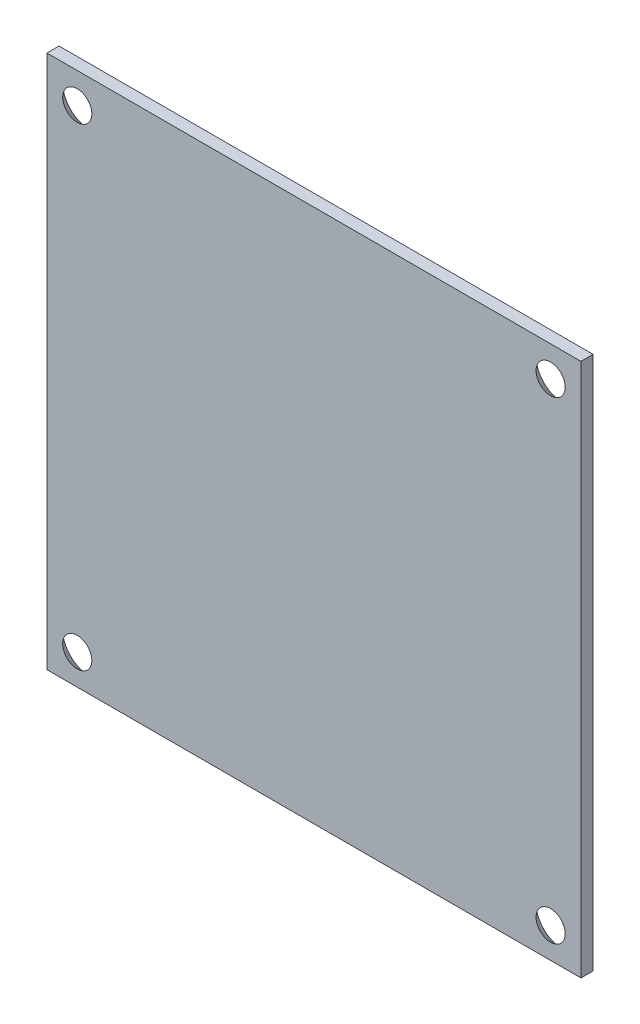
from build123d import *

# Parameters (mm, degrees)
ESQUISSE1_W                                 = 44
ESQUISSE1_H                                 = 44
BOSS_EXTRU_1_DEPTH                          = 1
FRAISAGE_POUR_VIS_T_TE_FRAIS_E_M21_AT_COUNT = 2
FRAISAGE_POUR_VIS_T_TE_FRAIS_E_M21_AT_PITCH = 39


with BuildPart() as part:
    # Esquisse1 → Boss.-Extru.1 (new body)
    with BuildSketch(Plane(origin=(0, 0, 0), x_dir=(0, 1, 0), z_dir=(0, 0, 1))):
        Rectangle(ESQUISSE1_W, ESQUISSE1_H)
    extrude(amount=BOSS_EXTRU_1_DEPTH)

    # Esquisse3 → Fraisage pour vis à tête fraisée M21 (revolve, cut)
    with BuildSketch(Plane(origin=(19.5, 19.5, 0), x_dir=(0, 1, 0), z_dir=(1, 0, 0))):
        Polygon((0, 0), (0, 2), (1.2, 2), (1.2, 1), (2.2, 0), align=None)
    fraisage_pour_vis_t_te_frais_e_m21 = revolve(axis=Axis((19.5, 19.5, -6.35), (0, 0, 1)), mode=Mode.SUBTRACT)

    # Fraisage pour vis à tête fraisée M21 at: Fraisage pour vis à tête fraisée M21 ×2
    with Locations(*[(-i * FRAISAGE_POUR_VIS_T_TE_FRAIS_E_M21_AT_PITCH, 0, 0) for i in range(1, FRAISAGE_POUR_VIS_T_TE_FRAIS_E_M21_AT_COUNT)]):
        add(fraisage_pour_vis_t_te_frais_e_m21, mode=Mode.SUBTRACT)

    # Symétrie2: Fraisage pour vis à tête fraisée M21 across plane
    add(fraisage_pour_vis_t_te_frais_e_m21.mirror(Plane.ZX), mode=Mode.SUBTRACT)

    # Symétrie2 copy 1 sketch → Symétrie2 copy 1 (revolve, cut)
    with BuildSketch(Plane(origin=(-19.5, -19.5, 0), x_dir=(0, -1, 0), z_dir=(1, 0, 0))):
        Polygon((0, 0), (0, -2), (1.2, -2), (1.2, -1), (2.2, 0), align=None)
    revolve(axis=Axis((-19.5, -19.5, -6.35), (0, 0, -1)), mode=Mode.SUBTRACT)


solid = part.part
